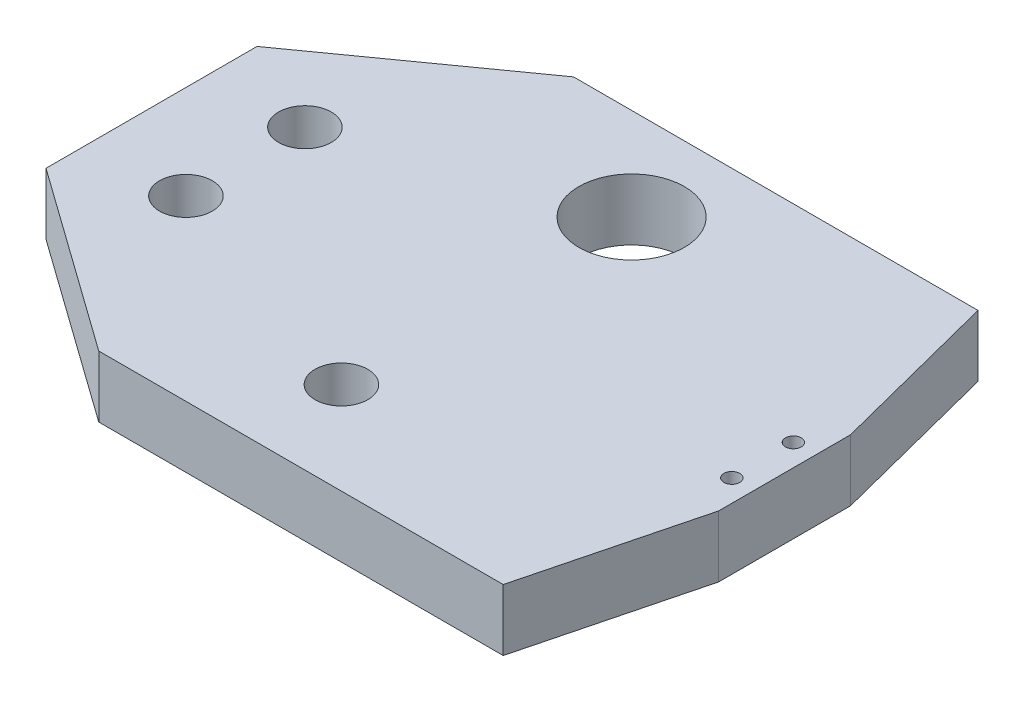
from build123d import *

# Parameters (mm, degrees)
BOSS_EXTRUDE1_DEPTH = 23.333333333
F_20_0MM_1_D        = 20
SCALE_1_SCALE       = 0.3
EXTRUDE_1_DEPTH     = 7
SKETCH_3_R          = 0.9
CUT_EXTRUDE_1_DEPTH = 8
SKETCH_4_R          = 6
CUT_EXTRUDE_2_DEPTH = 8


with BuildPart() as part:
    # Sketch2 → Boss-Extrude1 (new body)
    with BuildSketch(Plane(origin=(0, 0, 0), x_dir=(1, 0, 0), z_dir=(0, 1, 0))):
        Polygon((-170, -90), (-50, -90), (-50, 90), (-170, 90), (-240, 40), (-240, -40), align=None)
    extrude(amount=BOSS_EXTRUDE1_DEPTH)

    # Ø20.0mm 맞춤핀 구멍1 (through all)
    with Locations(Plane(origin=(0, 23.333333333, 0), x_dir=(1, 0, 0), z_dir=(0, 1, 0))):
        with Locations((-204.389232105, 22.557395049), (-204.389232105, -22.557395049), (-112.996294866, 55), (-112.996294866, -55)):
            Hole(F_20_0MM_1_D / 2)


with BuildPart() as part_1:
    # 축척1: scaled about (-135.896414653, 11.666666667, 0)
    add(part.part.scale(SCALE_1_SCALE).moved(Location((-95.127490257, 8.166666667, 0))))

    # 스케치1 → 보스-돌출1 (add)
    with BuildSketch(Plane(origin=(0, 15.166666667, 0), x_dir=(1, 0, 0), z_dir=(0, 1, 0))):
        Polygon((-95.127490257, -7.5), (-100.127490257, -27), (-110.127490257, -27), (-110.127490257, 27), (-100.127490257, 27), (-95.127490257, 7.5), align=None)
    extrude(amount=-EXTRUDE_1_DEPTH)

    # 스케치3 → 컷-돌출1 (cut, through all)
    with BuildSketch(Plane.XZ.offset(-8.166666667)):
        with Locations((-97.627490257, 3.5)):
            Circle(SKETCH_3_R)
        with Locations((-97.627490257, -3.5)):
            Circle(SKETCH_3_R)
    extrude(amount=-CUT_EXTRUDE_1_DEPTH, mode=Mode.SUBTRACT)

    # 스케치4 → 컷-돌출2 (cut, through all)
    with BuildSketch(Plane.XZ.offset(-8.166666667)):
        with Locations((-129.026378717, -16.5)):
            Circle(SKETCH_4_R)
    extrude(amount=-CUT_EXTRUDE_2_DEPTH, mode=Mode.SUBTRACT)


solid = part_1.part
